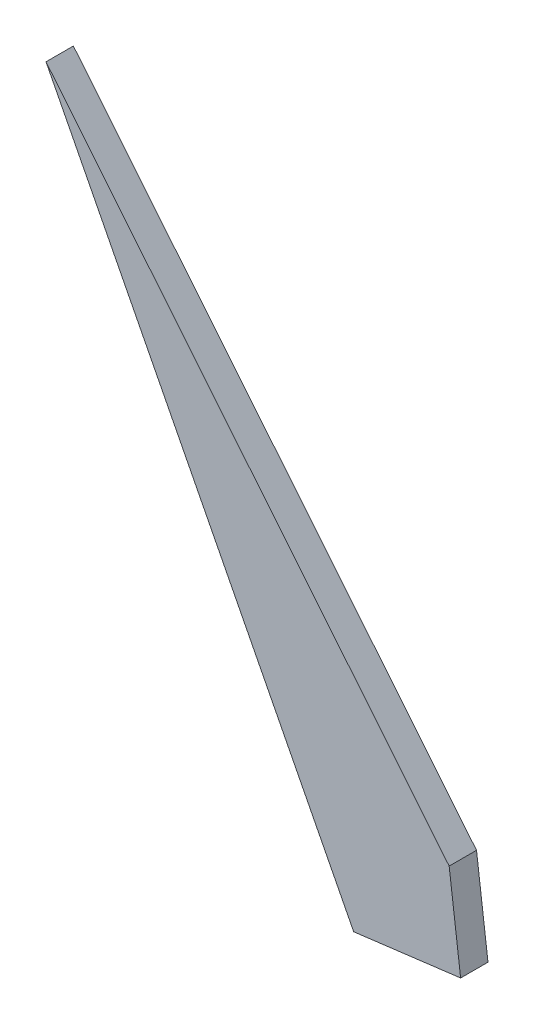
from build123d import *

# Parameters (mm, degrees)
BOSS_EXTRU_1_DEPTH = 3


with BuildPart() as part:
    # Esquisse1 → Boss.-Extru.1 (new body)
    with BuildSketch(Plane.XY):
        Polygon((-2.86929474, -1.227661982), (-47.077479113, 53.046055732), (-13.339571579, -12.701719764), (-1.612341656, -11.227661982), align=None)
    extrude(amount=BOSS_EXTRU_1_DEPTH)


solid = part.part
